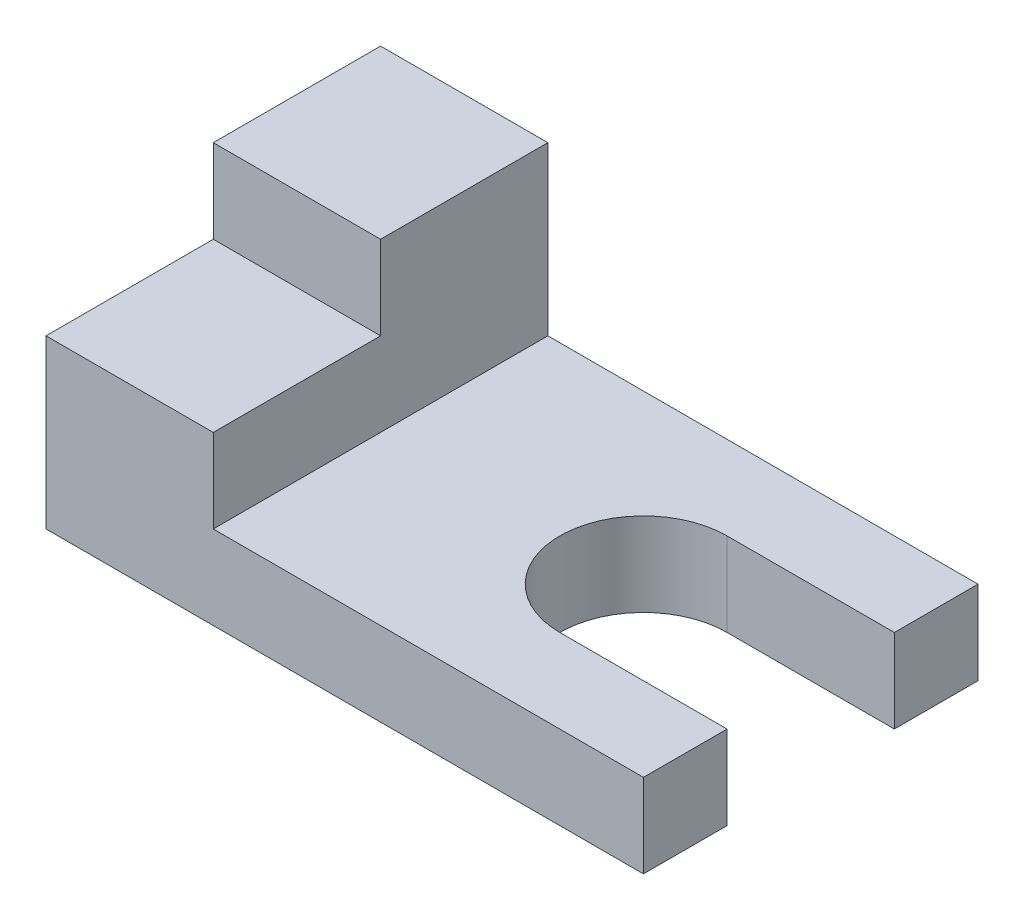
from build123d import *

# Parameters (mm, degrees)
BOSS_EXTRUDE1_DEPTH = 7
SKETCH2_W           = 14
SKETCH2_H           = 14
BOSS_EXTRUDE2_DEPTH = 7
SKETCH2_3_W         = 14
SKETCH2_3_H         = 14
BOSS_EXTRUDE3_DEPTH = 14


with BuildPart() as part:
    # Sketch1 → Boss-Extrude1 (new body)
    with BuildSketch(Plane(origin=(0, 0, 0), x_dir=(1, 0, 0), z_dir=(0, 1, 0))):
        with BuildLine():
            Line((0, -7), (0, -14))
            Line((0, -14), (-50, -14))
            Line((-50, -14), (-50, 0))
            Line((-50, 0), (-21, 0))
            ThreePointArc((-21, 0), (-18.949747468, -4.949747468), (-14, -7))
            Line((-14, -7), (0, -7))
        make_face()
    extrude(amount=BOSS_EXTRUDE1_DEPTH)

    # Mirror1: part across plane


with BuildPart() as part_1:
    add(part.part)
    add(part.part.mirror(Plane(origin=(-21, 7, 0), x_dir=(1, 0, 0), z_dir=(0, 0, 1))))

    # Sketch2 → Boss-Extrude2 (add)
    with BuildSketch(Plane(origin=(0, 7, 0), x_dir=(1, 0, 0), z_dir=(0, 1, 0))):
        with Locations((-43, -7)):
            Rectangle(SKETCH2_W, SKETCH2_H)
    extrude(amount=BOSS_EXTRUDE2_DEPTH)

    # Sketch2_3 → Boss-Extrude3 (add)
    with BuildSketch(Plane(origin=(0, 7, 0), x_dir=(1, 0, 0), z_dir=(0, 1, 0))):
        with Locations((-43, 7)):
            Rectangle(SKETCH2_3_W, SKETCH2_3_H)
    extrude(amount=BOSS_EXTRUDE3_DEPTH)


solid = part_1.part
